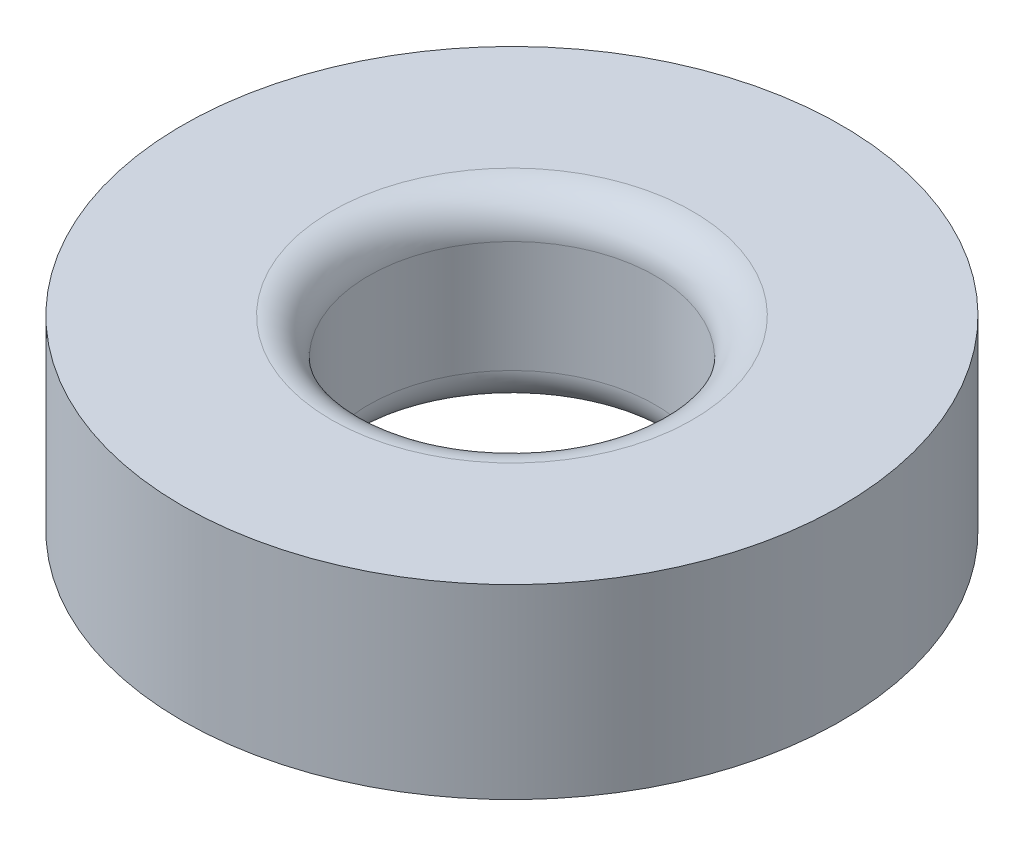
from build123d import *

# Parameters (mm, degrees)
SKETCH2_R           = 8.85
SKETCH2_R_2         = 3.85
BOSS_EXTRUDE1_DEPTH = 5
FILLET1_R           = 1


with BuildPart() as part:
    # Sketch2 → Boss-Extrude1 (new body)
    with BuildSketch(Plane(origin=(0, 0, 0), x_dir=(1, 0, 0), z_dir=(0, 1, 0))):
        Circle(SKETCH2_R)
        Circle(SKETCH2_R_2, mode=Mode.SUBTRACT)
    extrude(amount=BOSS_EXTRUDE1_DEPTH)

    # Fillet1
    fillet1_edges = [part.edges().sort_by_distance(p)[0] for p in [
        (-3.85, 0, 0),
        (-3.85, 5, 0),
    ]]
    fillet(fillet1_edges, radius=FILLET1_R)


solid = part.part
